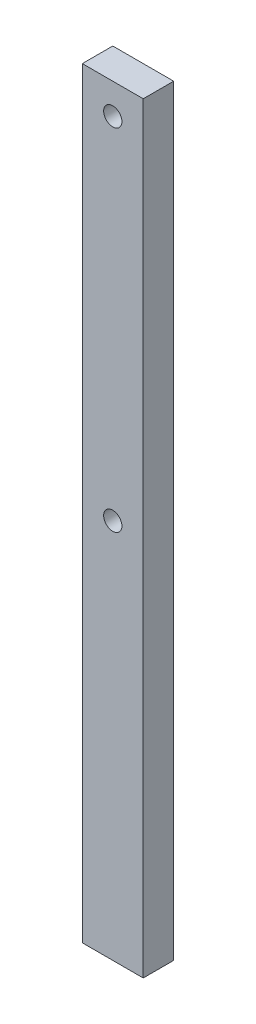
from build123d import *

# Parameters (mm, degrees)
SKETCH1_W           = 20
SKETCH1_H           = 250
BOSS_EXTRUDE1_DEPTH = 10
SKETCH2_R           = 3
CUT_EXTRUDE1_DEPTH  = 10


with BuildPart() as part:
    # Sketch1 → Boss-Extrude1 (new body)
    with BuildSketch(Plane.XY):
        Rectangle(SKETCH1_W, SKETCH1_H)
    extrude(amount=BOSS_EXTRUDE1_DEPTH)

    # Sketch2 → Cut-Extrude1 (cut)
    with BuildSketch(Plane.XY.offset(10)):
        with Locations((0, 115)):
            Circle(SKETCH2_R)
        Circle(SKETCH2_R)
    extrude(amount=-CUT_EXTRUDE1_DEPTH, mode=Mode.SUBTRACT)


solid = part.part
